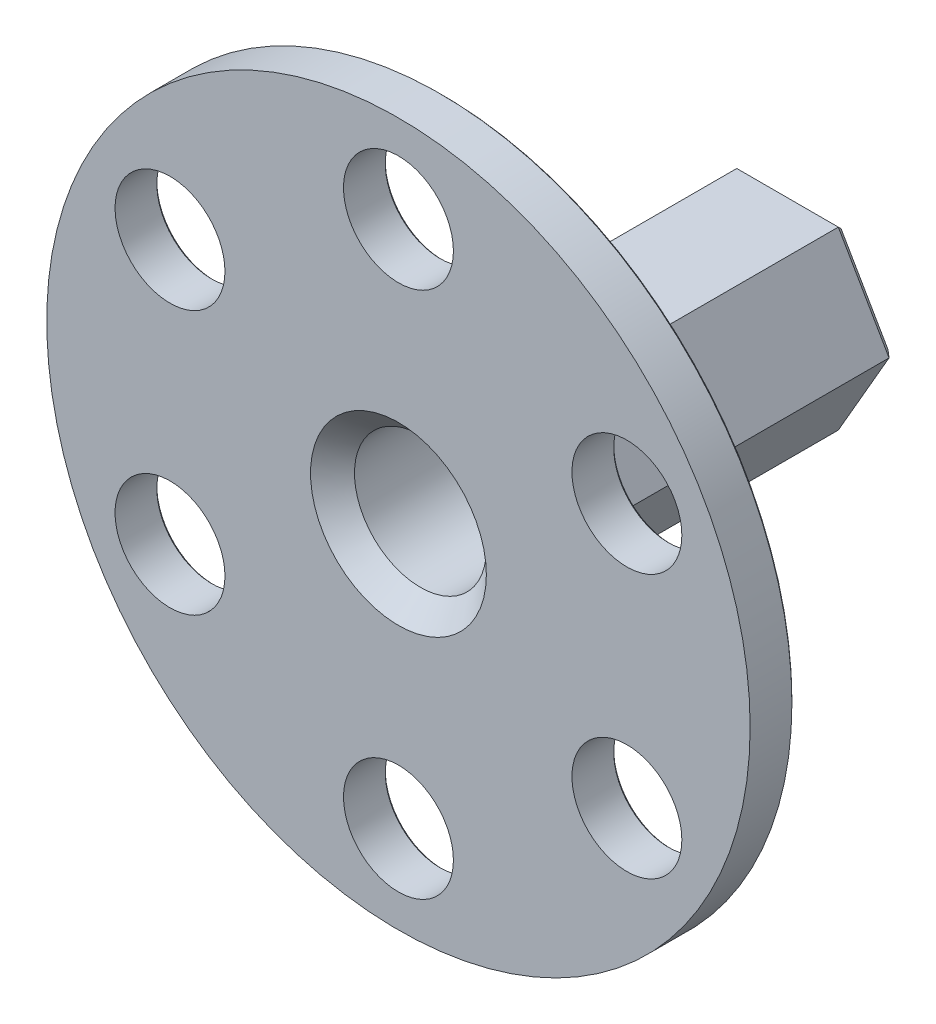
from build123d import *

# Parameters (mm, degrees)
SKETCH1_R           = 32
BOSS_EXTRUDE1_DEPTH = 4
SKETCH2_R           = 5
CUT_EXTRUDE1_DEPTH  = 5
CIRPATTERN1_COUNT   = 6
BOSS_EXTRUDE2_DEPTH = 32
CHAMFER1_SIZE       = 2
CHAMFER2_SIZE       = 0.2
SKETCH4_R           = 6
CUT_EXTRUDE2_DEPTH  = 32
CHAMFER3_SIZE       = 0.6
CHAMFER4_SIZE       = 5
CHAMFER5_SIZE       = 2


with BuildPart() as part:
    # Sketch1 → Boss-Extrude1 (new body)
    with BuildSketch(Plane.XY):
        Circle(SKETCH1_R)
    extrude(amount=-BOSS_EXTRUDE1_DEPTH)

    # Sketch2 → Cut-Extrude1 (cut, through all)
    with BuildSketch(Plane.XY):
        with Locations((0, 24)):
            Circle(SKETCH2_R)
    cut_extrude1 = extrude(amount=-CUT_EXTRUDE1_DEPTH, mode=Mode.SUBTRACT)

    # CirPattern1: Cut-Extrude1 ×6 about axis
    cirpattern1_axis = Axis((0, 0, 0), (0, 0, 1))
    for i in range(1, CIRPATTERN1_COUNT):
        add(cut_extrude1.rotate(cirpattern1_axis, i * 360 / CIRPATTERN1_COUNT), mode=Mode.SUBTRACT)

    # Sketch3 → Boss-Extrude2 (add)
    with BuildSketch(Plane(origin=(0, 0, -4), x_dir=(-1, 0, 0), z_dir=(0, 0, -1))):
        Polygon((-4.618802154, 8), (-9.237604307, 0), (-4.618802154, -8), (4.618802154, -8), (9.237604307, 0), (4.618802154, 8), align=None)
    extrude(amount=BOSS_EXTRUDE2_DEPTH)

    # Chamfer1
    chamfer1_edges = [part.edges().sort_by_distance(p)[0] for p in [
        (0, 8, -4),
        (6.92820323, 4, -4),
        (6.92820323, -4, -4),
        (0, -8, -4),
        (-6.92820323, -4, -4),
        (-6.92820323, 4, -4),
    ]]
    chamfer(chamfer1_edges, length=CHAMFER1_SIZE)

    # Chamfer2
    chamfer2_edges = [part.edges().sort_by_distance(p)[0] for p in [
        (-23.284609691, 7.669872981, -4),
        (-18.284609691, -16.330127019, -4),
        (5, -24, -4),
        (23.284609691, -7.669872981, -4),
        (18.284609691, 16.330127019, -4),
        (-32, 0, -4),
        (-5, 24, -4),
    ]]
    chamfer(chamfer2_edges, length=CHAMFER2_SIZE)

    # Sketch4 → Cut-Extrude2 (cut)
    with BuildSketch(Plane.XY):
        Circle(SKETCH4_R)
    extrude(amount=-CUT_EXTRUDE2_DEPTH, mode=Mode.SUBTRACT)

    # Chamfer3
    chamfer3_edges = [part.edges().sort_by_distance(p)[0] for p in [
        (0, 8, -36),
        (6.92820323, 4, -36),
        (6.92820323, -4, -36),
        (0, -8, -36),
        (-6.92820323, -4, -36),
        (-6.92820323, 4, -36),
    ]]
    chamfer(chamfer3_edges, length=CHAMFER3_SIZE)

    # Chamfer4
    chamfer4_edges = [part.edges().sort_by_distance(p)[0] for p in [
        (-6, 0, -32),
    ]]
    chamfer(chamfer4_edges, length=CHAMFER4_SIZE)

    # Chamfer5
    chamfer5_edges = [part.edges().sort_by_distance(p)[0] for p in [
        (-6, 0, 0),
    ]]
    chamfer(chamfer5_edges, length=CHAMFER5_SIZE)


solid = part.part
